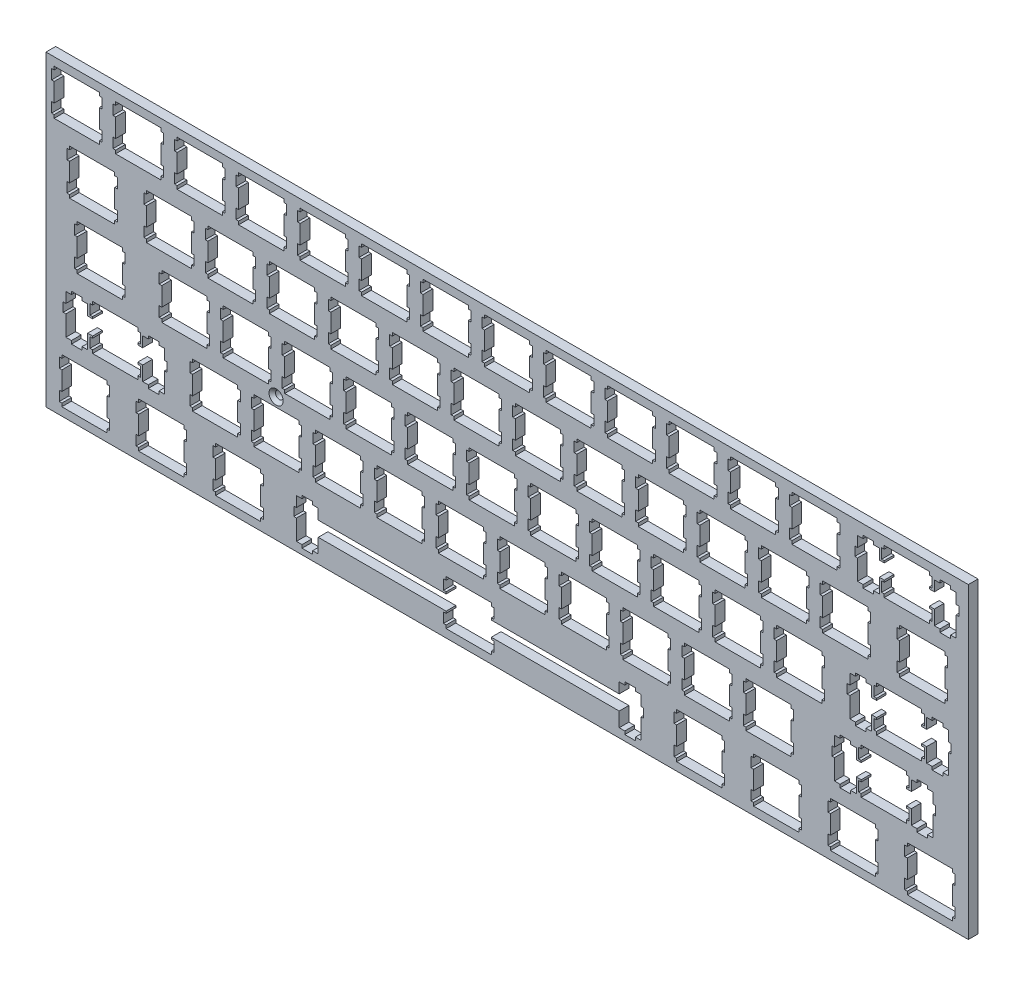
from build123d import *

# Parameters (mm, degrees)
MODEL_W                      = 285.7499154
MODEL_H                      = 95.249807
EXTRUDE_1_DEPTH              = 3
HOLE_WIZARD_M2_1_D           = 2.4
HOLE_WIZARD_M2_1_CSINK_D     = 4.4
HOLE_WIZARD_M2_1_CSINK_ANGLE = 90


with BuildPart() as part:
    # Model → 凸台-拉伸1 (new body)
    with BuildSketch(Plane.XY):
        with Locations((142.87505985, 47.624852359)):
            Rectangle(MODEL_W, MODEL_H)
        Polygon((123.96701755, 16.525355859), (123.96701755, 15.524955859), (123.16801755, 15.524955859), (123.16801755, 12.427055859), (123.96701755, 12.427055859), (123.96701755, 11.824855859), (84.34311755, 11.824855859), (84.34311755, 15.055055859), (82.61761755, 15.055055859), (82.61761755, 15.976955859), (79.31701755, 15.976955859), (79.31701755, 15.055055859), (77.59201755, 15.055055859), (77.59201755, 11.824855859), (76.76791755, 11.824855859), (76.76791755, 9.026095859), (77.59201755, 9.026095859), (77.59201755, 2.756025859), (79.31701755, 2.756025859), (79.31701755, 1.774865859), (82.61761755, 1.774865859), (82.61761755, 2.756025859), (84.34311755, 2.756025859), (84.34311755, 7.226365859), (123.96701755, 7.226365859), (123.96701755, 6.625545859), (123.16801755, 6.625545859), (123.16801755, 3.524985859), (123.96701755, 3.524985859), (123.96701755, 2.525895859), (137.96801755, 2.525895859), (137.96801755, 3.524985859), (138.76701755, 3.524985859), (138.76701755, 6.625545859), (137.96801755, 6.625545859), (137.96801755, 7.226365859), (177.59201755, 7.226365859), (177.59201755, 2.756025859), (179.31701755, 2.756025859), (179.31701755, 1.774865859), (182.61801755, 1.774865859), (182.61801755, 2.756025859), (184.34301755, 2.756025859), (184.34301755, 9.026095859), (185.16701755, 9.026095859), (185.16701755, 11.824855859), (184.34301755, 11.824855859), (184.34301755, 15.055055859), (182.61801755, 15.055055859), (182.61801755, 15.976955859), (179.31701755, 15.976955859), (179.31701755, 15.055055859), (177.59201755, 15.055055859), (177.59201755, 11.824855859), (137.96801755, 11.824855859), (137.96801755, 12.427055859), (138.76701755, 12.427055859), (138.76701755, 15.524955859), (137.96801755, 15.524955859), (137.96801755, 16.525355859), align=None, mode=Mode.SUBTRACT)
        Polygon((266.84201755, 16.525355859), (266.84201755, 15.524955859), (266.04301755, 15.524955859), (266.04301755, 12.427055859), (266.84201755, 12.427055859), (266.84201755, 6.625545859), (266.04301755, 6.625545859), (266.04301755, 3.524985859), (266.84201755, 3.524985859), (266.84201755, 2.525895859), (280.84301755, 2.525895859), (280.84301755, 3.524985859), (281.64201755, 3.524985859), (281.64201755, 6.625545859), (280.84301755, 6.625545859), (280.84301755, 12.427055859), (281.64201755, 12.427055859), (281.64201755, 15.524955859), (280.84301755, 15.524955859), (280.84301755, 16.525355859), align=None, mode=Mode.SUBTRACT)
        Polygon((243.03101755, 16.525355859), (243.03101755, 15.524955859), (242.23001755, 15.524955859), (242.23001755, 12.427055859), (243.03101755, 12.427055859), (243.03101755, 6.625545859), (242.23001755, 6.625545859), (242.23001755, 3.524985859), (243.03101755, 3.524985859), (243.03101755, 2.525895859), (257.03001755, 2.525895859), (257.03001755, 3.524985859), (257.83101755, 3.524985859), (257.83101755, 6.625545859), (257.03001755, 6.625545859), (257.03001755, 12.427055859), (257.83101755, 12.427055859), (257.83101755, 15.524955859), (257.03001755, 15.524955859), (257.03001755, 16.525355859), align=None, mode=Mode.SUBTRACT)
        Polygon((219.21701755, 16.525355859), (219.21701755, 15.524955859), (218.41801755, 15.524955859), (218.41801755, 12.427055859), (219.21701755, 12.427055859), (219.21701755, 6.625545859), (218.41801755, 6.625545859), (218.41801755, 3.524985859), (219.21701755, 3.524985859), (219.21701755, 2.525895859), (233.21801755, 2.525895859), (233.21801755, 3.524985859), (234.01701755, 3.524985859), (234.01701755, 6.625545859), (233.21801755, 6.625545859), (233.21801755, 12.427055859), (234.01701755, 12.427055859), (234.01701755, 15.524955859), (233.21801755, 15.524955859), (233.21801755, 16.525355859), align=None, mode=Mode.SUBTRACT)
        Polygon((195.40601755, 16.525355859), (195.40601755, 15.524955859), (194.60501755, 15.524955859), (194.60501755, 12.427055859), (195.40601755, 12.427055859), (195.40601755, 6.625545859), (194.60501755, 6.625545859), (194.60501755, 3.524985859), (195.40601755, 3.524985859), (195.40601755, 2.525895859), (209.40501755, 2.525895859), (209.40501755, 3.524985859), (210.20601755, 3.524985859), (210.20601755, 6.625545859), (209.40501755, 6.625545859), (209.40501755, 12.427055859), (210.20601755, 12.427055859), (210.20601755, 15.524955859), (209.40501755, 15.524955859), (209.40501755, 16.525355859), align=None, mode=Mode.SUBTRACT)
        Polygon((52.53101755, 16.525355859), (52.53101755, 15.524955859), (51.73021755, 15.524955859), (51.73021755, 12.427055859), (52.53101755, 12.427055859), (52.53101755, 6.625545859), (51.73021755, 6.625545859), (51.73021755, 3.524985859), (52.53101755, 3.524985859), (52.53101755, 2.525895859), (66.53031755, 2.525895859), (66.53031755, 3.524985859), (67.33111755, 3.524985859), (67.33111755, 6.625545859), (66.53031755, 6.625545859), (66.53031755, 12.427055859), (67.33111755, 12.427055859), (67.33111755, 15.524955859), (66.53031755, 15.524955859), (66.53031755, 16.525355859), align=None, mode=Mode.SUBTRACT)
        Polygon((28.71701755, 16.525355859), (28.71701755, 15.524955859), (27.91781755, 15.524955859), (27.91781755, 12.427055859), (28.71701755, 12.427055859), (28.71701755, 6.625545859), (27.91781755, 6.625545859), (27.91781755, 3.524985859), (28.71701755, 3.524985859), (28.71701755, 2.525895859), (42.71781755, 2.525895859), (42.71781755, 3.524985859), (43.51721755, 3.524985859), (43.51721755, 6.625545859), (42.71781755, 6.625545859), (42.71781755, 12.427055859), (43.51721755, 12.427055859), (43.51721755, 15.524955859), (42.71781755, 15.524955859), (42.71781755, 16.525355859), align=None, mode=Mode.SUBTRACT)
        Polygon((4.90592755, 16.525355859), (4.90592755, 15.524955859), (4.10529755, 15.524955859), (4.10529755, 12.427055859), (4.90592755, 12.427055859), (4.90592755, 6.625545859), (4.10529755, 6.625545859), (4.10529755, 3.524985859), (4.90592755, 3.524985859), (4.90592755, 2.525895859), (18.90541755, 2.525895859), (18.90541755, 3.524985859), (19.70601755, 3.524985859), (19.70601755, 6.625545859), (18.90541755, 6.625545859), (18.90541755, 12.427055859), (19.70601755, 12.427055859), (19.70601755, 15.524955859), (18.90541755, 15.524955859), (18.90541755, 16.525355859), align=None, mode=Mode.SUBTRACT)
        Polygon((252.55501755, 35.575255859), (252.55501755, 34.574955859), (251.75401755, 34.574955859), (251.75401755, 31.477055859), (252.55501755, 31.477055859), (252.55501755, 30.874855859), (251.03101755, 30.874855859), (251.03101755, 34.105055859), (249.30501755, 34.105055859), (249.30501755, 35.027055859), (246.00601755, 35.027055859), (246.00601755, 34.105055859), (244.28101755, 34.105055859), (244.28101755, 30.874855859), (243.45501755, 30.874855859), (243.45501755, 28.076055859), (244.28101755, 28.076055859), (244.28101755, 21.806055859), (246.00601755, 21.806055859), (246.00601755, 20.824855859), (249.30501755, 20.824855859), (249.30501755, 21.806055859), (251.03101755, 21.806055859), (251.03101755, 26.274955859), (252.55501755, 26.274955859), (252.55501755, 25.675555859), (251.75401755, 25.675555859), (251.75401755, 22.574955859), (252.55501755, 22.574955859), (252.55501755, 21.575855859), (266.55501755, 21.575855859), (266.55501755, 22.574955859), (267.35601755, 22.574955859), (267.35601755, 25.675555859), (266.55501755, 25.675555859), (266.55501755, 26.274955859), (268.08101755, 26.274955859), (268.08101755, 21.806055859), (269.80501755, 21.806055859), (269.80501755, 20.824855859), (273.10501755, 20.824855859), (273.10501755, 21.806055859), (274.83001755, 21.806055859), (274.83001755, 28.076055859), (275.65601755, 28.076055859), (275.65601755, 30.874855859), (274.83001755, 30.874855859), (274.83001755, 34.105055859), (273.10501755, 34.105055859), (273.10501755, 35.027055859), (269.80501755, 35.027055859), (269.80501755, 34.105055859), (268.08101755, 34.105055859), (268.08101755, 30.874855859), (266.55501755, 30.874855859), (266.55501755, 31.477055859), (267.35601755, 31.477055859), (267.35601755, 34.574955859), (266.55501755, 34.574955859), (266.55501755, 35.575255859), align=None, mode=Mode.SUBTRACT)
        Polygon((14.43091755, 35.575255859), (14.43091755, 34.574955859), (13.63031755, 34.574955859), (13.63031755, 31.477055859), (14.43091755, 31.477055859), (14.43091755, 30.874855859), (12.90541755, 30.874855859), (12.90541755, 34.105055859), (11.18011755, 34.105055859), (11.18011755, 35.027055859), (7.88110755, 35.027055859), (7.88110755, 34.105055859), (6.15581755, 34.105055859), (6.15581755, 30.874855859), (5.33034755, 30.874855859), (5.33034755, 28.076055859), (6.15581755, 28.076055859), (6.15581755, 21.806055859), (7.88110755, 21.806055859), (7.88110755, 20.824855859), (11.18011755, 20.824855859), (11.18011755, 21.806055859), (12.90541755, 21.806055859), (12.90541755, 26.274955859), (14.43091755, 26.274955859), (14.43091755, 25.675555859), (13.63031755, 25.675555859), (13.63031755, 22.574955859), (14.43091755, 22.574955859), (14.43091755, 21.575855859), (28.43041755, 21.575855859), (28.43041755, 22.574955859), (29.23101755, 22.574955859), (29.23101755, 25.675555859), (28.43041755, 25.675555859), (28.43041755, 26.274955859), (29.95591755, 26.274955859), (29.95591755, 21.806055859), (31.67981755, 21.806055859), (31.67981755, 20.824855859), (34.98021755, 20.824855859), (34.98021755, 21.806055859), (36.70541755, 21.806055859), (36.70541755, 28.076055859), (37.53091755, 28.076055859), (37.53091755, 30.874855859), (36.70541755, 30.874855859), (36.70541755, 34.105055859), (34.98021755, 34.105055859), (34.98021755, 35.027055859), (31.67981755, 35.027055859), (31.67981755, 34.105055859), (29.95591755, 34.105055859), (29.95591755, 30.874855859), (28.43041755, 30.874855859), (28.43041755, 31.477055859), (29.23101755, 31.477055859), (29.23101755, 34.574955859), (28.43041755, 34.574955859), (28.43041755, 35.575255859), align=None, mode=Mode.SUBTRACT)
        Polygon((216.83701755, 35.575255859), (216.83701755, 34.574955859), (216.03601755, 34.574955859), (216.03601755, 31.477055859), (216.83701755, 31.477055859), (216.83701755, 25.675555859), (216.03601755, 25.675555859), (216.03601755, 22.574955859), (216.83701755, 22.574955859), (216.83701755, 21.575855859), (230.83701755, 21.575855859), (230.83701755, 22.574955859), (231.63601755, 22.574955859), (231.63601755, 25.675555859), (230.83701755, 25.675555859), (230.83701755, 31.477055859), (231.63601755, 31.477055859), (231.63601755, 34.574955859), (230.83701755, 34.574955859), (230.83701755, 35.575255859), align=None, mode=Mode.SUBTRACT)
        Polygon((197.78701755, 35.575255859), (197.78701755, 34.574955859), (196.98601755, 34.574955859), (196.98601755, 31.477055859), (197.78701755, 31.477055859), (197.78701755, 25.675555859), (196.98601755, 25.675555859), (196.98601755, 22.574955859), (197.78701755, 22.574955859), (197.78701755, 21.575855859), (211.78701755, 21.575855859), (211.78701755, 22.574955859), (212.58601755, 22.574955859), (212.58601755, 25.675555859), (211.78701755, 25.675555859), (211.78701755, 31.477055859), (212.58601755, 31.477055859), (212.58601755, 34.574955859), (211.78701755, 34.574955859), (211.78701755, 35.575255859), align=None, mode=Mode.SUBTRACT)
        Polygon((178.73701755, 35.575255859), (178.73701755, 34.574955859), (177.93601755, 34.574955859), (177.93601755, 31.477055859), (178.73701755, 31.477055859), (178.73701755, 25.675555859), (177.93601755, 25.675555859), (177.93601755, 22.574955859), (178.73701755, 22.574955859), (178.73701755, 21.575855859), (192.73701755, 21.575855859), (192.73701755, 22.574955859), (193.53601755, 22.574955859), (193.53601755, 25.675555859), (192.73701755, 25.675555859), (192.73701755, 31.477055859), (193.53601755, 31.477055859), (193.53601755, 34.574955859), (192.73701755, 34.574955859), (192.73701755, 35.575255859), align=None, mode=Mode.SUBTRACT)
        Polygon((159.68701755, 35.575255859), (159.68701755, 34.574955859), (158.88601755, 34.574955859), (158.88601755, 31.477055859), (159.68701755, 31.477055859), (159.68701755, 25.675555859), (158.88601755, 25.675555859), (158.88601755, 22.574955859), (159.68701755, 22.574955859), (159.68701755, 21.575855859), (173.68701755, 21.575855859), (173.68701755, 22.574955859), (174.48601755, 22.574955859), (174.48601755, 25.675555859), (173.68701755, 25.675555859), (173.68701755, 31.477055859), (174.48601755, 31.477055859), (174.48601755, 34.574955859), (173.68701755, 34.574955859), (173.68701755, 35.575255859), align=None, mode=Mode.SUBTRACT)
        Polygon((140.63701755, 35.575255859), (140.63701755, 34.574955859), (139.83601755, 34.574955859), (139.83601755, 31.477055859), (140.63701755, 31.477055859), (140.63701755, 25.675555859), (139.83601755, 25.675555859), (139.83601755, 22.574955859), (140.63701755, 22.574955859), (140.63701755, 21.575855859), (154.63701755, 21.575855859), (154.63701755, 22.574955859), (155.43601755, 22.574955859), (155.43601755, 25.675555859), (154.63701755, 25.675555859), (154.63701755, 31.477055859), (155.43601755, 31.477055859), (155.43601755, 34.574955859), (154.63701755, 34.574955859), (154.63701755, 35.575255859), align=None, mode=Mode.SUBTRACT)
        Polygon((121.58701755, 35.575255859), (121.58701755, 34.574955859), (120.78601755, 34.574955859), (120.78601755, 31.477055859), (121.58701755, 31.477055859), (121.58701755, 25.675555859), (120.78601755, 25.675555859), (120.78601755, 22.574955859), (121.58701755, 22.574955859), (121.58701755, 21.575855859), (135.58701755, 21.575855859), (135.58701755, 22.574955859), (136.38601755, 22.574955859), (136.38601755, 25.675555859), (135.58701755, 25.675555859), (135.58701755, 31.477055859), (136.38601755, 31.477055859), (136.38601755, 34.574955859), (135.58701755, 34.574955859), (135.58701755, 35.575255859), align=None, mode=Mode.SUBTRACT)
        Polygon((102.53701755, 35.575255859), (102.53701755, 34.574955859), (101.73601755, 34.574955859), (101.73601755, 31.477055859), (102.53701755, 31.477055859), (102.53701755, 25.675555859), (101.73601755, 25.675555859), (101.73601755, 22.574955859), (102.53701755, 22.574955859), (102.53701755, 21.575855859), (116.53701755, 21.575855859), (116.53701755, 22.574955859), (117.33601755, 22.574955859), (117.33601755, 25.675555859), (116.53701755, 25.675555859), (116.53701755, 31.477055859), (117.33601755, 31.477055859), (117.33601755, 34.574955859), (116.53701755, 34.574955859), (116.53701755, 35.575255859), align=None, mode=Mode.SUBTRACT)
        Polygon((83.48721755, 35.575255859), (83.48721755, 34.574955859), (82.68641755, 34.574955859), (82.68641755, 31.477055859), (83.48721755, 31.477055859), (83.48721755, 25.675555859), (82.68641755, 25.675555859), (82.68641755, 22.574955859), (83.48721755, 22.574955859), (83.48721755, 21.575855859), (97.48651755, 21.575855859), (97.48651755, 22.574955859), (98.28591755, 22.574955859), (98.28591755, 25.675555859), (97.48651755, 25.675555859), (97.48651755, 31.477055859), (98.28591755, 31.477055859), (98.28591755, 34.574955859), (97.48651755, 34.574955859), (97.48651755, 35.575255859), align=None, mode=Mode.SUBTRACT)
        Polygon((64.43721755, 35.575255859), (64.43721755, 34.574955859), (63.63641755, 34.574955859), (63.63641755, 31.477055859), (64.43721755, 31.477055859), (64.43721755, 25.675555859), (63.63641755, 25.675555859), (63.63641755, 22.574955859), (64.43721755, 22.574955859), (64.43721755, 21.575855859), (78.43651755, 21.575855859), (78.43651755, 22.574955859), (79.23591755, 22.574955859), (79.23591755, 25.675555859), (78.43651755, 25.675555859), (78.43651755, 31.477055859), (79.23591755, 31.477055859), (79.23591755, 34.574955859), (78.43651755, 34.574955859), (78.43651755, 35.575255859), align=None, mode=Mode.SUBTRACT)
        Polygon((45.38721755, 35.575255859), (45.38721755, 34.574955859), (44.58641755, 34.574955859), (44.58641755, 31.477055859), (45.38721755, 31.477055859), (45.38721755, 25.675555859), (44.58641755, 25.675555859), (44.58641755, 22.574955859), (45.38721755, 22.574955859), (45.38721755, 21.575855859), (59.38651755, 21.575855859), (59.38651755, 22.574955859), (60.18591755, 22.574955859), (60.18591755, 25.675555859), (59.38651755, 25.675555859), (59.38651755, 31.477055859), (60.18591755, 31.477055859), (60.18591755, 34.574955859), (59.38651755, 34.574955859), (59.38651755, 35.575255859), align=None, mode=Mode.SUBTRACT)
        Polygon((257.31701755, 54.625355859), (257.31701755, 53.624855859), (256.51601755, 53.624855859), (256.51601755, 50.525655859), (257.31701755, 50.525655859), (257.31701755, 49.924855859), (255.79301755, 49.924855859), (255.79301755, 53.154955859), (254.06601755, 53.154955859), (254.06601755, 54.075655859), (250.76701755, 54.075655859), (250.76701755, 53.154955859), (249.04201755, 53.154955859), (249.04201755, 49.924855859), (248.21801755, 49.924855859), (248.21801755, 47.125955859), (249.04201755, 47.125955859), (249.04201755, 40.856055859), (250.76701755, 40.856055859), (250.76701755, 39.874955859), (254.06601755, 39.874955859), (254.06601755, 40.856055859), (255.79301755, 40.856055859), (255.79301755, 45.325055859), (257.31701755, 45.325055859), (257.31701755, 44.725655859), (256.51601755, 44.725655859), (256.51601755, 41.625055859), (257.31701755, 41.625055859), (257.31701755, 40.626055859), (271.31801755, 40.626055859), (271.31801755, 41.625055859), (272.11701755, 41.625055859), (272.11701755, 44.725655859), (271.31801755, 44.725655859), (271.31801755, 45.325055859), (272.84201755, 45.325055859), (272.84201755, 40.856055859), (274.56701755, 40.856055859), (274.56701755, 39.874955859), (277.86801755, 39.874955859), (277.86801755, 40.856055859), (279.59301755, 40.856055859), (279.59301755, 47.125955859), (280.41701755, 47.125955859), (280.41701755, 49.924855859), (279.59301755, 49.924855859), (279.59301755, 53.154955859), (277.86801755, 53.154955859), (277.86801755, 54.075655859), (274.56701755, 54.075655859), (274.56701755, 53.154955859), (272.84201755, 53.154955859), (272.84201755, 49.924855859), (271.31801755, 49.924855859), (271.31801755, 50.525655859), (272.11701755, 50.525655859), (272.11701755, 53.624855859), (271.31801755, 53.624855859), (271.31801755, 54.625355859), align=None, mode=Mode.SUBTRACT)
        Polygon((226.36201755, 54.625355859), (226.36201755, 53.624855859), (225.56101755, 53.624855859), (225.56101755, 50.525655859), (226.36201755, 50.525655859), (226.36201755, 44.725655859), (225.56101755, 44.725655859), (225.56101755, 41.625055859), (226.36201755, 41.625055859), (226.36201755, 40.626055859), (240.36201755, 40.626055859), (240.36201755, 41.625055859), (241.16101755, 41.625055859), (241.16101755, 44.725655859), (240.36201755, 44.725655859), (240.36201755, 50.525655859), (241.16101755, 50.525655859), (241.16101755, 53.624855859), (240.36201755, 53.624855859), (240.36201755, 54.625355859), align=None, mode=Mode.SUBTRACT)
        Polygon((207.31201755, 54.625355859), (207.31201755, 53.624855859), (206.51101755, 53.624855859), (206.51101755, 50.525655859), (207.31201755, 50.525655859), (207.31201755, 44.725655859), (206.51101755, 44.725655859), (206.51101755, 41.625055859), (207.31201755, 41.625055859), (207.31201755, 40.626055859), (221.31201755, 40.626055859), (221.31201755, 41.625055859), (222.11101755, 41.625055859), (222.11101755, 44.725655859), (221.31201755, 44.725655859), (221.31201755, 50.525655859), (222.11101755, 50.525655859), (222.11101755, 53.624855859), (221.31201755, 53.624855859), (221.31201755, 54.625355859), align=None, mode=Mode.SUBTRACT)
        Polygon((188.26201755, 54.625355859), (188.26201755, 53.624855859), (187.46101755, 53.624855859), (187.46101755, 50.525655859), (188.26201755, 50.525655859), (188.26201755, 44.725655859), (187.46101755, 44.725655859), (187.46101755, 41.625055859), (188.26201755, 41.625055859), (188.26201755, 40.626055859), (202.26201755, 40.626055859), (202.26201755, 41.625055859), (203.06101755, 41.625055859), (203.06101755, 44.725655859), (202.26201755, 44.725655859), (202.26201755, 50.525655859), (203.06101755, 50.525655859), (203.06101755, 53.624855859), (202.26201755, 53.624855859), (202.26201755, 54.625355859), align=None, mode=Mode.SUBTRACT)
        Polygon((169.21201755, 54.625355859), (169.21201755, 53.624855859), (168.41101755, 53.624855859), (168.41101755, 50.525655859), (169.21201755, 50.525655859), (169.21201755, 44.725655859), (168.41101755, 44.725655859), (168.41101755, 41.625055859), (169.21201755, 41.625055859), (169.21201755, 40.626055859), (183.21201755, 40.626055859), (183.21201755, 41.625055859), (184.01101755, 41.625055859), (184.01101755, 44.725655859), (183.21201755, 44.725655859), (183.21201755, 50.525655859), (184.01101755, 50.525655859), (184.01101755, 53.624855859), (183.21201755, 53.624855859), (183.21201755, 54.625355859), align=None, mode=Mode.SUBTRACT)
        Polygon((150.16201755, 54.625355859), (150.16201755, 53.624855859), (149.36101755, 53.624855859), (149.36101755, 50.525655859), (150.16201755, 50.525655859), (150.16201755, 44.725655859), (149.36101755, 44.725655859), (149.36101755, 41.625055859), (150.16201755, 41.625055859), (150.16201755, 40.626055859), (164.16201755, 40.626055859), (164.16201755, 41.625055859), (164.96101755, 41.625055859), (164.96101755, 44.725655859), (164.16201755, 44.725655859), (164.16201755, 50.525655859), (164.96101755, 50.525655859), (164.96101755, 53.624855859), (164.16201755, 53.624855859), (164.16201755, 54.625355859), align=None, mode=Mode.SUBTRACT)
        Polygon((131.11201755, 54.625355859), (131.11201755, 53.624855859), (130.31101755, 53.624855859), (130.31101755, 50.525655859), (131.11201755, 50.525655859), (131.11201755, 44.725655859), (130.31101755, 44.725655859), (130.31101755, 41.625055859), (131.11201755, 41.625055859), (131.11201755, 40.626055859), (145.11201755, 40.626055859), (145.11201755, 41.625055859), (145.91101755, 41.625055859), (145.91101755, 44.725655859), (145.11201755, 44.725655859), (145.11201755, 50.525655859), (145.91101755, 50.525655859), (145.91101755, 53.624855859), (145.11201755, 53.624855859), (145.11201755, 54.625355859), align=None, mode=Mode.SUBTRACT)
        Polygon((112.06201755, 54.625355859), (112.06201755, 53.624855859), (111.26101755, 53.624855859), (111.26101755, 50.525655859), (112.06201755, 50.525655859), (112.06201755, 44.725655859), (111.26101755, 44.725655859), (111.26101755, 41.625055859), (112.06201755, 41.625055859), (112.06201755, 40.626055859), (126.06201755, 40.626055859), (126.06201755, 41.625055859), (126.86101755, 41.625055859), (126.86101755, 44.725655859), (126.06201755, 44.725655859), (126.06201755, 50.525655859), (126.86101755, 50.525655859), (126.86101755, 53.624855859), (126.06201755, 53.624855859), (126.06201755, 54.625355859), align=None, mode=Mode.SUBTRACT)
        Polygon((93.01221755, 54.625355859), (93.01221755, 53.624855859), (92.21141755, 53.624855859), (92.21141755, 50.525655859), (93.01221755, 50.525655859), (93.01221755, 44.725655859), (92.21141755, 44.725655859), (92.21141755, 41.625055859), (93.01221755, 41.625055859), (93.01221755, 40.626055859), (107.01201755, 40.626055859), (107.01201755, 41.625055859), (107.81101755, 41.625055859), (107.81101755, 44.725655859), (107.01201755, 44.725655859), (107.01201755, 50.525655859), (107.81101755, 50.525655859), (107.81101755, 53.624855859), (107.01201755, 53.624855859), (107.01201755, 54.625355859), align=None, mode=Mode.SUBTRACT)
        Polygon((73.96221755, 54.625355859), (73.96221755, 53.624855859), (73.16141755, 53.624855859), (73.16141755, 50.525655859), (73.96221755, 50.525655859), (73.96221755, 44.725655859), (73.16141755, 44.725655859), (73.16141755, 41.625055859), (73.96221755, 41.625055859), (73.96221755, 40.626055859), (87.96151755, 40.626055859), (87.96151755, 41.625055859), (88.76091755, 41.625055859), (88.76091755, 44.725655859), (87.96151755, 44.725655859), (87.96151755, 50.525655859), (88.76091755, 50.525655859), (88.76091755, 53.624855859), (87.96151755, 53.624855859), (87.96151755, 54.625355859), align=None, mode=Mode.SUBTRACT)
        Polygon((54.91221755, 54.625355859), (54.91221755, 53.624855859), (54.11141755, 53.624855859), (54.11141755, 50.525655859), (54.91221755, 50.525655859), (54.91221755, 44.725655859), (54.11141755, 44.725655859), (54.11141755, 41.625055859), (54.91221755, 41.625055859), (54.91221755, 40.626055859), (68.91151755, 40.626055859), (68.91151755, 41.625055859), (69.71091755, 41.625055859), (69.71091755, 44.725655859), (68.91151755, 44.725655859), (68.91151755, 50.525655859), (69.71091755, 50.525655859), (69.71091755, 53.624855859), (68.91151755, 53.624855859), (68.91151755, 54.625355859), align=None, mode=Mode.SUBTRACT)
        Polygon((35.86221755, 54.625355859), (35.86221755, 53.624855859), (35.06151755, 53.624855859), (35.06151755, 50.525655859), (35.86221755, 50.525655859), (35.86221755, 44.725655859), (35.06151755, 44.725655859), (35.06151755, 41.625055859), (35.86221755, 41.625055859), (35.86221755, 40.626055859), (49.86151755, 40.626055859), (49.86151755, 41.625055859), (50.66091755, 41.625055859), (50.66091755, 44.725655859), (49.86151755, 44.725655859), (49.86151755, 50.525655859), (50.66091755, 50.525655859), (50.66091755, 53.624855859), (49.86151755, 53.624855859), (49.86151755, 54.625355859), align=None, mode=Mode.SUBTRACT)
        Polygon((9.66704755, 54.625355859), (9.66704755, 53.624855859), (8.86779755, 53.624855859), (8.86779755, 50.525655859), (9.66704755, 50.525655859), (9.66704755, 44.725655859), (8.86779755, 44.725655859), (8.86779755, 41.625055859), (9.66704755, 41.625055859), (9.66704755, 40.626055859), (23.66791755, 40.626055859), (23.66791755, 41.625055859), (24.46721755, 41.625055859), (24.46721755, 44.725655859), (23.66791755, 44.725655859), (23.66791755, 50.525655859), (24.46721755, 50.525655859), (24.46721755, 53.624855859), (23.66791755, 53.624855859), (23.66791755, 54.625355859), align=None, mode=Mode.SUBTRACT)
        Polygon((264.46201755, 73.675355859), (264.46201755, 72.674855859), (263.66101755, 72.674855859), (263.66101755, 69.575655859), (264.46201755, 69.575655859), (264.46201755, 63.775655859), (263.66101755, 63.775655859), (263.66101755, 60.675055859), (264.46201755, 60.675055859), (264.46201755, 59.676055859), (278.46201755, 59.676055859), (278.46201755, 60.675055859), (279.26101755, 60.675055859), (279.26101755, 63.775655859), (278.46201755, 63.775655859), (278.46201755, 69.575655859), (279.26101755, 69.575655859), (279.26101755, 72.674855859), (278.46201755, 72.674855859), (278.46201755, 73.675355859), align=None, mode=Mode.SUBTRACT)
        Polygon((240.65001755, 73.675355859), (240.65001755, 72.674855859), (239.84901755, 72.674855859), (239.84901755, 69.575655859), (240.65001755, 69.575655859), (240.65001755, 63.775655859), (239.84901755, 63.775655859), (239.84901755, 60.675055859), (240.65001755, 60.675055859), (240.65001755, 59.676055859), (254.64901755, 59.676055859), (254.64901755, 60.675055859), (255.45001755, 60.675055859), (255.45001755, 63.775655859), (254.64901755, 63.775655859), (254.64901755, 69.575655859), (255.45001755, 69.575655859), (255.45001755, 72.674855859), (254.64901755, 72.674855859), (254.64901755, 73.675355859), align=None, mode=Mode.SUBTRACT)
        Polygon((221.60001755, 73.675355859), (221.60001755, 72.674855859), (220.79901755, 72.674855859), (220.79901755, 69.575655859), (221.60001755, 69.575655859), (221.60001755, 63.775655859), (220.79901755, 63.775655859), (220.79901755, 60.675055859), (221.60001755, 60.675055859), (221.60001755, 59.676055859), (235.59901755, 59.676055859), (235.59901755, 60.675055859), (236.40001755, 60.675055859), (236.40001755, 63.775655859), (235.59901755, 63.775655859), (235.59901755, 69.575655859), (236.40001755, 69.575655859), (236.40001755, 72.674855859), (235.59901755, 72.674855859), (235.59901755, 73.675355859), align=None, mode=Mode.SUBTRACT)
        Polygon((202.55001755, 73.675355859), (202.55001755, 72.674855859), (201.74901755, 72.674855859), (201.74901755, 69.575655859), (202.55001755, 69.575655859), (202.55001755, 63.775655859), (201.74901755, 63.775655859), (201.74901755, 60.675055859), (202.55001755, 60.675055859), (202.55001755, 59.676055859), (216.54901755, 59.676055859), (216.54901755, 60.675055859), (217.35001755, 60.675055859), (217.35001755, 63.775655859), (216.54901755, 63.775655859), (216.54901755, 69.575655859), (217.35001755, 69.575655859), (217.35001755, 72.674855859), (216.54901755, 72.674855859), (216.54901755, 73.675355859), align=None, mode=Mode.SUBTRACT)
        Polygon((183.50001755, 73.675355859), (183.50001755, 72.674855859), (182.69901755, 72.674855859), (182.69901755, 69.575655859), (183.50001755, 69.575655859), (183.50001755, 63.775655859), (182.69901755, 63.775655859), (182.69901755, 60.675055859), (183.50001755, 60.675055859), (183.50001755, 59.676055859), (197.49901755, 59.676055859), (197.49901755, 60.675055859), (198.30001755, 60.675055859), (198.30001755, 63.775655859), (197.49901755, 63.775655859), (197.49901755, 69.575655859), (198.30001755, 69.575655859), (198.30001755, 72.674855859), (197.49901755, 72.674855859), (197.49901755, 73.675355859), align=None, mode=Mode.SUBTRACT)
        Polygon((164.45001755, 73.675355859), (164.45001755, 72.674855859), (163.64901755, 72.674855859), (163.64901755, 69.575655859), (164.45001755, 69.575655859), (164.45001755, 63.775655859), (163.64901755, 63.775655859), (163.64901755, 60.675055859), (164.45001755, 60.675055859), (164.45001755, 59.676055859), (178.44901755, 59.676055859), (178.44901755, 60.675055859), (179.25001755, 60.675055859), (179.25001755, 63.775655859), (178.44901755, 63.775655859), (178.44901755, 69.575655859), (179.25001755, 69.575655859), (179.25001755, 72.674855859), (178.44901755, 72.674855859), (178.44901755, 73.675355859), align=None, mode=Mode.SUBTRACT)
        Polygon((145.40001755, 73.675355859), (145.40001755, 72.674855859), (144.59901755, 72.674855859), (144.59901755, 69.575655859), (145.40001755, 69.575655859), (145.40001755, 63.775655859), (144.59901755, 63.775655859), (144.59901755, 60.675055859), (145.40001755, 60.675055859), (145.40001755, 59.676055859), (159.39901755, 59.676055859), (159.39901755, 60.675055859), (160.20001755, 60.675055859), (160.20001755, 63.775655859), (159.39901755, 63.775655859), (159.39901755, 69.575655859), (160.20001755, 69.575655859), (160.20001755, 72.674855859), (159.39901755, 72.674855859), (159.39901755, 73.675355859), align=None, mode=Mode.SUBTRACT)
        Polygon((126.35001755, 73.675355859), (126.35001755, 72.674855859), (125.54901755, 72.674855859), (125.54901755, 69.575655859), (126.35001755, 69.575655859), (126.35001755, 63.775655859), (125.54901755, 63.775655859), (125.54901755, 60.675055859), (126.35001755, 60.675055859), (126.35001755, 59.676055859), (140.34901755, 59.676055859), (140.34901755, 60.675055859), (141.15001755, 60.675055859), (141.15001755, 63.775655859), (140.34901755, 63.775655859), (140.34901755, 69.575655859), (141.15001755, 69.575655859), (141.15001755, 72.674855859), (140.34901755, 72.674855859), (140.34901755, 73.675355859), align=None, mode=Mode.SUBTRACT)
        Polygon((107.30001755, 73.675355859), (107.30001755, 72.674855859), (106.49901755, 72.674855859), (106.49901755, 69.575655859), (107.30001755, 69.575655859), (107.30001755, 63.775655859), (106.49901755, 63.775655859), (106.49901755, 60.675055859), (107.30001755, 60.675055859), (107.30001755, 59.676055859), (121.29901755, 59.676055859), (121.29901755, 60.675055859), (122.10001755, 60.675055859), (122.10001755, 63.775655859), (121.29901755, 63.775655859), (121.29901755, 69.575655859), (122.10001755, 69.575655859), (122.10001755, 72.674855859), (121.29901755, 72.674855859), (121.29901755, 73.675355859), align=None, mode=Mode.SUBTRACT)
        Polygon((88.24971755, 73.675355859), (88.24971755, 72.674855859), (87.44891755, 72.674855859), (87.44891755, 69.575655859), (88.24971755, 69.575655859), (88.24971755, 63.775655859), (87.44891755, 63.775655859), (87.44891755, 60.675055859), (88.24971755, 60.675055859), (88.24971755, 59.676055859), (102.24901755, 59.676055859), (102.24901755, 60.675055859), (103.05001755, 60.675055859), (103.05001755, 63.775655859), (102.24901755, 63.775655859), (102.24901755, 69.575655859), (103.05001755, 69.575655859), (103.05001755, 72.674855859), (102.24901755, 72.674855859), (102.24901755, 73.675355859), align=None, mode=Mode.SUBTRACT)
        Polygon((69.19971755, 73.675355859), (69.19971755, 72.674855859), (68.39891755, 72.674855859), (68.39891755, 69.575655859), (69.19971755, 69.575655859), (69.19971755, 63.775655859), (68.39891755, 63.775655859), (68.39891755, 60.675055859), (69.19971755, 60.675055859), (69.19971755, 59.676055859), (83.19901755, 59.676055859), (83.19901755, 60.675055859), (83.99981755, 60.675055859), (83.99981755, 63.775655859), (83.19901755, 63.775655859), (83.19901755, 69.575655859), (83.99981755, 69.575655859), (83.99981755, 72.674855859), (83.19901755, 72.674855859), (83.19901755, 73.675355859), align=None, mode=Mode.SUBTRACT)
        Polygon((50.14971755, 73.675355859), (50.14971755, 72.674855859), (49.34891755, 72.674855859), (49.34891755, 69.575655859), (50.14971755, 69.575655859), (50.14971755, 63.775655859), (49.34891755, 63.775655859), (49.34891755, 60.675055859), (50.14971755, 60.675055859), (50.14971755, 59.676055859), (64.14901755, 59.676055859), (64.14901755, 60.675055859), (64.94981755, 60.675055859), (64.94981755, 63.775655859), (64.14901755, 63.775655859), (64.14901755, 69.575655859), (64.94981755, 69.575655859), (64.94981755, 72.674855859), (64.14901755, 72.674855859), (64.14901755, 73.675355859), align=None, mode=Mode.SUBTRACT)
        Polygon((31.09971755, 73.675355859), (31.09971755, 72.674855859), (30.29901755, 72.674855859), (30.29901755, 69.575655859), (31.09971755, 69.575655859), (31.09971755, 63.775655859), (30.29901755, 63.775655859), (30.29901755, 60.675055859), (31.09971755, 60.675055859), (31.09971755, 59.676055859), (45.09901755, 59.676055859), (45.09901755, 60.675055859), (45.89981755, 60.675055859), (45.89981755, 63.775655859), (45.09901755, 63.775655859), (45.09901755, 69.575655859), (45.89981755, 69.575655859), (45.89981755, 72.674855859), (45.09901755, 72.674855859), (45.09901755, 73.675355859), align=None, mode=Mode.SUBTRACT)
        Polygon((7.28717755, 73.675355859), (7.28717755, 72.674855859), (6.48654755, 72.674855859), (6.48654755, 69.575655859), (7.28717755, 69.575655859), (7.28717755, 63.775655859), (6.48654755, 63.775655859), (6.48654755, 60.675055859), (7.28717755, 60.675055859), (7.28717755, 59.676055859), (21.28671755, 59.676055859), (21.28671755, 60.675055859), (22.08591755, 60.675055859), (22.08591755, 63.775655859), (21.28671755, 63.775655859), (21.28671755, 69.575655859), (22.08591755, 69.575655859), (22.08591755, 72.674855859), (21.28671755, 72.674855859), (21.28671755, 73.675355859), align=None, mode=Mode.SUBTRACT)
        Polygon((259.70001755, 92.725355859), (259.70001755, 91.724855859), (258.89901755, 91.724855859), (258.89901755, 88.625655859), (259.70001755, 88.625655859), (259.70001755, 88.024855859), (258.17401755, 88.024855859), (258.17401755, 91.254955859), (256.44901755, 91.254955859), (256.44901755, 92.177055859), (253.14801755, 92.177055859), (253.14801755, 91.254955859), (251.42501755, 91.254955859), (251.42501755, 88.024855859), (250.59901755, 88.024855859), (250.59901755, 85.225955859), (251.42501755, 85.225955859), (251.42501755, 78.956055859), (253.14801755, 78.956055859), (253.14801755, 77.974955859), (256.44901755, 77.974955859), (256.44901755, 78.956055859), (258.17401755, 78.956055859), (258.17401755, 83.425055859), (259.70001755, 83.425055859), (259.70001755, 82.825655859), (258.89901755, 82.825655859), (258.89901755, 79.725055859), (259.70001755, 79.725055859), (259.70001755, 78.726055859), (273.69901755, 78.726055859), (273.69901755, 79.725055859), (274.50001755, 79.725055859), (274.50001755, 82.825655859), (273.69901755, 82.825655859), (273.69901755, 83.425055859), (275.22501755, 83.425055859), (275.22501755, 78.956055859), (276.95001755, 78.956055859), (276.95001755, 77.974955859), (280.24901755, 77.974955859), (280.24901755, 78.956055859), (281.97401755, 78.956055859), (281.97401755, 85.225955859), (282.80001755, 85.225955859), (282.80001755, 88.024855859), (281.97401755, 88.024855859), (281.97401755, 91.254955859), (280.24901755, 91.254955859), (280.24901755, 92.177055859), (276.95001755, 92.177055859), (276.95001755, 91.254955859), (275.22501755, 91.254955859), (275.22501755, 88.024855859), (273.69901755, 88.024855859), (273.69901755, 88.625655859), (274.50001755, 88.625655859), (274.50001755, 91.724855859), (273.69901755, 91.724855859), (273.69901755, 92.725355859), align=None, mode=Mode.SUBTRACT)
        Polygon((231.12501755, 92.725355859), (231.12501755, 91.724855859), (230.32401755, 91.724855859), (230.32401755, 88.625655859), (231.12501755, 88.625655859), (231.12501755, 82.825655859), (230.32401755, 82.825655859), (230.32401755, 79.725055859), (231.12501755, 79.725055859), (231.12501755, 78.726055859), (245.12401755, 78.726055859), (245.12401755, 79.725055859), (245.92501755, 79.725055859), (245.92501755, 82.825655859), (245.12401755, 82.825655859), (245.12401755, 88.625655859), (245.92501755, 88.625655859), (245.92501755, 91.724855859), (245.12401755, 91.724855859), (245.12401755, 92.725355859), align=None, mode=Mode.SUBTRACT)
        Polygon((212.07501755, 92.725355859), (212.07501755, 91.724855859), (211.27401755, 91.724855859), (211.27401755, 88.625655859), (212.07501755, 88.625655859), (212.07501755, 82.825655859), (211.27401755, 82.825655859), (211.27401755, 79.725055859), (212.07501755, 79.725055859), (212.07501755, 78.726055859), (226.07401755, 78.726055859), (226.07401755, 79.725055859), (226.87501755, 79.725055859), (226.87501755, 82.825655859), (226.07401755, 82.825655859), (226.07401755, 88.625655859), (226.87501755, 88.625655859), (226.87501755, 91.724855859), (226.07401755, 91.724855859), (226.07401755, 92.725355859), align=None, mode=Mode.SUBTRACT)
        Polygon((193.02501755, 92.725355859), (193.02501755, 91.724855859), (192.22401755, 91.724855859), (192.22401755, 88.625655859), (193.02501755, 88.625655859), (193.02501755, 82.825655859), (192.22401755, 82.825655859), (192.22401755, 79.725055859), (193.02501755, 79.725055859), (193.02501755, 78.726055859), (207.02401755, 78.726055859), (207.02401755, 79.725055859), (207.82501755, 79.725055859), (207.82501755, 82.825655859), (207.02401755, 82.825655859), (207.02401755, 88.625655859), (207.82501755, 88.625655859), (207.82501755, 91.724855859), (207.02401755, 91.724855859), (207.02401755, 92.725355859), align=None, mode=Mode.SUBTRACT)
        Polygon((173.97501755, 92.725355859), (173.97501755, 91.724855859), (173.17401755, 91.724855859), (173.17401755, 88.625655859), (173.97501755, 88.625655859), (173.97501755, 82.825655859), (173.17401755, 82.825655859), (173.17401755, 79.725055859), (173.97501755, 79.725055859), (173.97501755, 78.726055859), (187.97401755, 78.726055859), (187.97401755, 79.725055859), (188.77501755, 79.725055859), (188.77501755, 82.825655859), (187.97401755, 82.825655859), (187.97401755, 88.625655859), (188.77501755, 88.625655859), (188.77501755, 91.724855859), (187.97401755, 91.724855859), (187.97401755, 92.725355859), align=None, mode=Mode.SUBTRACT)
        Polygon((154.92501755, 92.725355859), (154.92501755, 91.724855859), (154.12401755, 91.724855859), (154.12401755, 88.625655859), (154.92501755, 88.625655859), (154.92501755, 82.825655859), (154.12401755, 82.825655859), (154.12401755, 79.725055859), (154.92501755, 79.725055859), (154.92501755, 78.726055859), (168.92401755, 78.726055859), (168.92401755, 79.725055859), (169.72501755, 79.725055859), (169.72501755, 82.825655859), (168.92401755, 82.825655859), (168.92401755, 88.625655859), (169.72501755, 88.625655859), (169.72501755, 91.724855859), (168.92401755, 91.724855859), (168.92401755, 92.725355859), align=None, mode=Mode.SUBTRACT)
        Polygon((135.87501755, 92.725355859), (135.87501755, 91.724855859), (135.07401755, 91.724855859), (135.07401755, 88.625655859), (135.87501755, 88.625655859), (135.87501755, 82.825655859), (135.07401755, 82.825655859), (135.07401755, 79.725055859), (135.87501755, 79.725055859), (135.87501755, 78.726055859), (149.87401755, 78.726055859), (149.87401755, 79.725055859), (150.67501755, 79.725055859), (150.67501755, 82.825655859), (149.87401755, 82.825655859), (149.87401755, 88.625655859), (150.67501755, 88.625655859), (150.67501755, 91.724855859), (149.87401755, 91.724855859), (149.87401755, 92.725355859), align=None, mode=Mode.SUBTRACT)
        Polygon((116.82301755, 92.725355859), (116.82301755, 91.724855859), (116.02401755, 91.724855859), (116.02401755, 88.625655859), (116.82301755, 88.625655859), (116.82301755, 82.825655859), (116.02401755, 82.825655859), (116.02401755, 79.725055859), (116.82301755, 79.725055859), (116.82301755, 78.726055859), (130.82401755, 78.726055859), (130.82401755, 79.725055859), (131.62501755, 79.725055859), (131.62501755, 82.825655859), (130.82401755, 82.825655859), (130.82401755, 88.625655859), (131.62501755, 88.625655859), (131.62501755, 91.724855859), (130.82401755, 91.724855859), (130.82401755, 92.725355859), align=None, mode=Mode.SUBTRACT)
        Polygon((97.77331755, 92.725355859), (97.77331755, 91.724855859), (96.97391755, 91.724855859), (96.97391755, 88.625655859), (97.77331755, 88.625655859), (97.77331755, 82.825655859), (96.97391755, 82.825655859), (96.97391755, 79.725055859), (97.77331755, 79.725055859), (97.77331755, 78.726055859), (111.77401755, 78.726055859), (111.77401755, 79.725055859), (112.57301755, 79.725055859), (112.57301755, 82.825655859), (111.77401755, 82.825655859), (111.77401755, 88.625655859), (112.57301755, 88.625655859), (112.57301755, 91.724855859), (111.77401755, 91.724855859), (111.77401755, 92.725355859), align=None, mode=Mode.SUBTRACT)
        Polygon((78.72471755, 92.725355859), (78.72471755, 91.724855859), (77.92391755, 91.724855859), (77.92391755, 88.625655859), (78.72471755, 88.625655859), (78.72471755, 82.825655859), (77.92391755, 82.825655859), (77.92391755, 79.725055859), (78.72471755, 79.725055859), (78.72471755, 78.726055859), (92.72401755, 78.726055859), (92.72401755, 79.725055859), (93.52341755, 79.725055859), (93.52341755, 82.825655859), (92.72401755, 82.825655859), (92.72401755, 88.625655859), (93.52341755, 88.625655859), (93.52341755, 91.724855859), (92.72401755, 91.724855859), (92.72401755, 92.725355859), align=None, mode=Mode.SUBTRACT)
        Polygon((59.67471755, 92.725355859), (59.67471755, 91.724855859), (58.87391755, 91.724855859), (58.87391755, 88.625655859), (59.67471755, 88.625655859), (59.67471755, 82.825655859), (58.87391755, 82.825655859), (58.87391755, 79.725055859), (59.67471755, 79.725055859), (59.67471755, 78.726055859), (73.67401755, 78.726055859), (73.67401755, 79.725055859), (74.47481755, 79.725055859), (74.47481755, 82.825655859), (73.67401755, 82.825655859), (73.67401755, 88.625655859), (74.47481755, 88.625655859), (74.47481755, 91.724855859), (73.67401755, 91.724855859), (73.67401755, 92.725355859), align=None, mode=Mode.SUBTRACT)
        Polygon((40.62471755, 92.725355859), (40.62471755, 91.724855859), (39.82391755, 91.724855859), (39.82391755, 88.625655859), (40.62471755, 88.625655859), (40.62471755, 82.825655859), (39.82391755, 82.825655859), (39.82391755, 79.725055859), (40.62471755, 79.725055859), (40.62471755, 78.726055859), (54.62401755, 78.726055859), (54.62401755, 79.725055859), (55.42481755, 79.725055859), (55.42481755, 82.825655859), (54.62401755, 82.825655859), (54.62401755, 88.625655859), (55.42481755, 88.625655859), (55.42481755, 91.724855859), (54.62401755, 91.724855859), (54.62401755, 92.725355859), align=None, mode=Mode.SUBTRACT)
        Polygon((21.57471755, 92.725355859), (21.57471755, 91.724855859), (20.77401755, 91.724855859), (20.77401755, 88.625655859), (21.57471755, 88.625655859), (21.57471755, 82.825655859), (20.77401755, 82.825655859), (20.77401755, 79.725055859), (21.57471755, 79.725055859), (21.57471755, 78.726055859), (35.57401755, 78.726055859), (35.57401755, 79.725055859), (36.37481755, 79.725055859), (36.37481755, 82.825655859), (35.57401755, 82.825655859), (35.57401755, 88.625655859), (36.37481755, 88.625655859), (36.37481755, 91.724855859), (35.57401755, 91.724855859), (35.57401755, 92.725355859), align=None, mode=Mode.SUBTRACT)
        Polygon((2.52466755, 92.725355859), (2.52466755, 91.724855859), (1.72402755, 91.724855859), (1.72402755, 88.625655859), (2.52466755, 88.625655859), (2.52466755, 82.825655859), (1.72402755, 82.825655859), (1.72402755, 79.725055859), (2.52466755, 79.725055859), (2.52466755, 78.726055859), (16.52421755, 78.726055859), (16.52421755, 79.725055859), (17.32481755, 79.725055859), (17.32481755, 82.825655859), (16.52421755, 82.825655859), (16.52421755, 88.625655859), (17.32481755, 88.625655859), (17.32481755, 91.724855859), (16.52421755, 91.724855859), (16.52421755, 92.725355859), align=None, mode=Mode.SUBTRACT)
    extrude(amount=EXTRUDE_1_DEPTH)

    # M2 十字切槽平头螺钉锥孔1 (through all)
    with Locations(Plane.XY.offset(3)):
        with Locations((71.291572689, 38.356946954)):
            CounterSinkHole(HOLE_WIZARD_M2_1_D / 2, HOLE_WIZARD_M2_1_CSINK_D / 2, counter_sink_angle=HOLE_WIZARD_M2_1_CSINK_ANGLE)


solid = part.part
